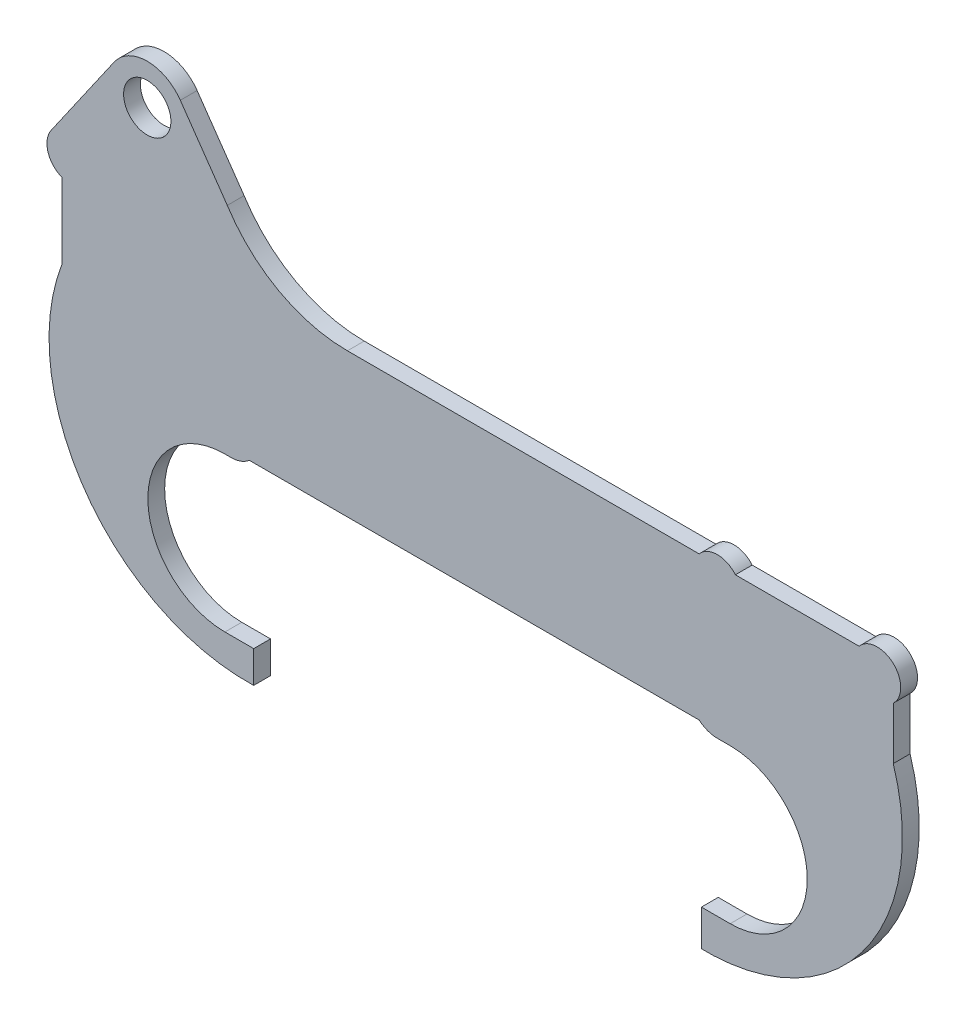
from build123d import *

# Parameters (mm, degrees)
SKETCH1_R           = 9.398
BOSS_EXTRUDE1_DEPTH = 6.6802


with BuildPart() as part:
    # Sketch1 → Boss-Extrude1 (new body)
    with BuildSketch(Plane.XY):
        with BuildLine():
            ThreePointArc((67.2719, -2.667), (71.112502584, -1.978843865), (74.475234217, 0))
            Line((74.475234217, 0), (253.108565783, 0))
            ThreePointArc((253.108565783, 0), (256.471297416, -1.978843865), (260.3119, -2.667))
            Line((260.3119, -2.667), (265.43, -2.667))
            ThreePointArc((265.43, -2.667), (296.037, -33.274), (265.43, -63.881))
            Line((265.43, -63.881), (254, -63.881))
            Line((254, -63.881), (254, -78.192462102))
            Line((254, -78.192462102), (258.804744722, -78.192462102))
            ThreePointArc((258.804744722, -78.192462102), (319.641243362, -44.945714973), (330.2, 23.573905719))
            Line((330.2, 23.573905719), (330.2, 44.344229198))
            ThreePointArc((330.2, 44.344229198), (330.227085405, 57.966090028), (316.629665681, 57.15))
            Line((316.629665681, 57.15), (267.494134319, 57.15))
            ThreePointArc((267.494134319, 57.15), (260.3119, 60.515088497), (253.129665681, 57.15))
            Line((253.129665681, 57.15), (113.415260688, 57.15))
            ThreePointArc((113.415260688, 57.15), (86.208048701, 64.123551226), (65.709724775, 83.324632368))
            Line((65.709724775, 83.324632368), (47.058503367, 110.140244689))
            ThreePointArc((47.058503367, 110.140244689), (33.921662387, 117.0051), (20.784821408, 110.140244689))
            Line((20.784821408, 110.140244689), (2.1336, 83.324632368))
            Line((2.1336, 83.324632368), (-4.235992095, 74.166813235))
            ThreePointArc((-4.235992095, 74.166813235), (-5.510617618, 66.127763534), (0, 60.137431006))
            Line((0, 60.137431006), (0, 30.088432035))
            ThreePointArc((0, 30.088432035), (8.908195227, -42.581537647), (73.7489, -76.581))
            ThreePointArc((73.7489, -76.581), (74.974598175, -76.57147033), (76.2, -76.542883623))
            Line((76.2, -76.542883623), (76.2, -63.881))
            Line((76.2, -63.881), (64.77, -63.881))
            ThreePointArc((64.77, -63.881), (34.163, -33.274), (64.77, -2.667))
            Line((64.77, -2.667), (67.2719, -2.667))
        make_face()
        with Locations((33.921662387, 101.0031)):
            Circle(SKETCH1_R, mode=Mode.SUBTRACT)
    extrude(amount=BOSS_EXTRUDE1_DEPTH)


solid = part.part
